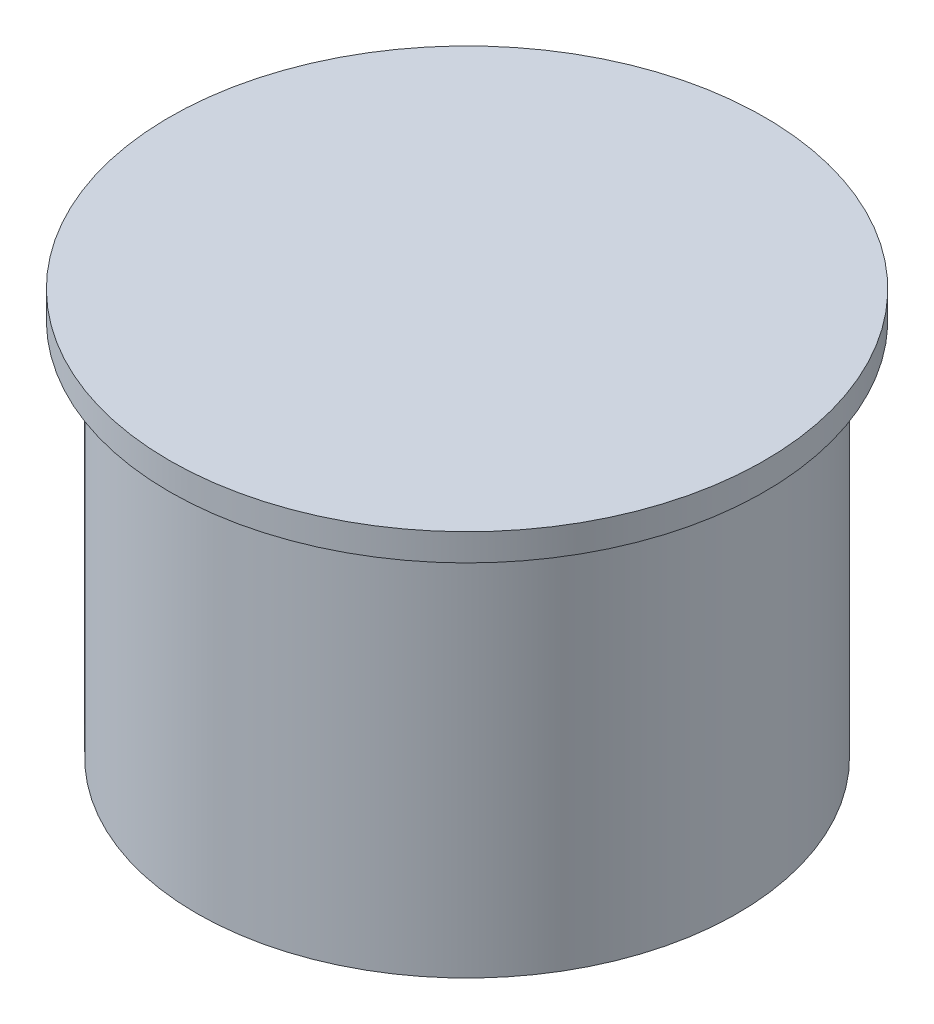
from build123d import *

# Parameters (mm, degrees)
SKETCH2_R          = 4
CUT_EXTRUDE1_DEPTH = 30


with BuildPart() as part:
    # Sketch1 → Revolve1 (revolve)
    with BuildSketch(Plane(origin=(0, 0, 0), x_dir=(0, 0, -1), z_dir=(1, 0, 0))):
        Polygon((0, 0), (50, 0), (50, 70), (55, 70), (55, 75), (0, 75), align=None)
    revolve(axis=Axis((0, 75, 0), (0, -1, 0)))

    # Sketch2 → Cut-Extrude1 (cut)
    with BuildSketch(Plane.XZ):
        with Locations((-24.748737342, 24.748737342)):
            Circle(SKETCH2_R)
        with Locations((24.748737342, 24.748737342)):
            Circle(SKETCH2_R)
        with Locations((24.748737342, -24.748737342)):
            Circle(SKETCH2_R)
        with Locations((-24.748737342, -24.748737342)):
            Circle(SKETCH2_R)
    extrude(amount=-CUT_EXTRUDE1_DEPTH, mode=Mode.SUBTRACT)


solid = part.part
